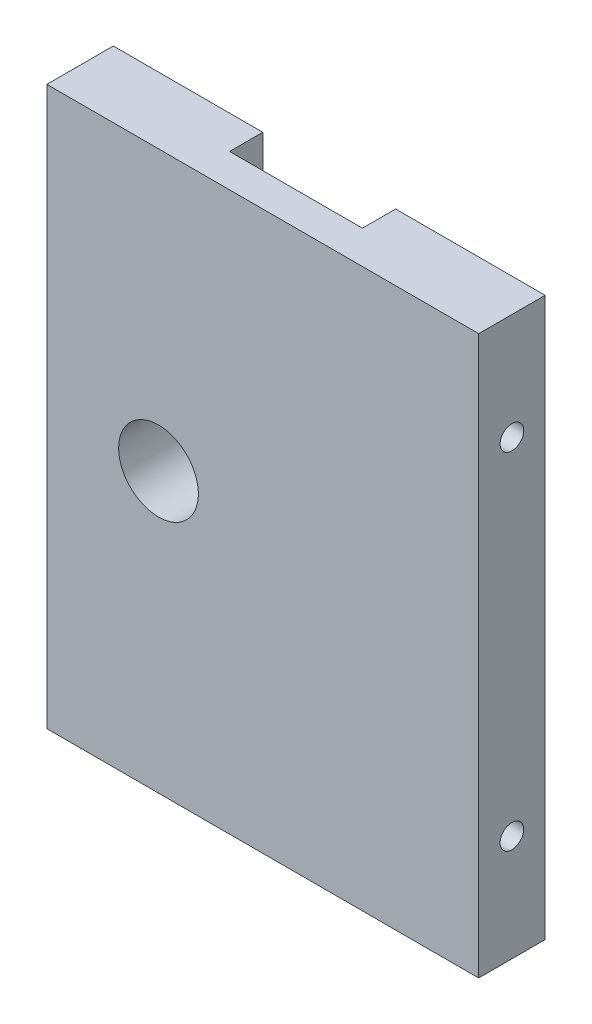
from build123d import *

# Parameters (mm, degrees)
SKETCH1_W                 = 32.5
SKETCH1_H                 = 42
BOSS_EXTRUDE2_DEPTH       = 5
F_2_56_TAPPED_HOLE1_D     = 1.778
F_2_56_TAPPED_HOLE1_DEPTH = 7.46583491
F_2_56_TAPPED_HOLE1_TIP   = 0.53416509
F_2_56_TAPPED_HOLE2_D     = 1.778
F_2_56_TAPPED_HOLE2_DEPTH = 7.46583491
F_2_56_TAPPED_HOLE2_TIP   = 0.53416509
CUT_EXTRUDE1_DEPTH        = 5
SKETCH10_W                = 10
SKETCH10_H                = 6.5
CUT_EXTRUDE2_DEPTH        = 2.5


with BuildPart() as part:
    # Sketch1 → Boss-Extrude2 (new body)
    with BuildSketch(Plane.XY):
        with Locations((16.25, 21)):
            Rectangle(SKETCH1_W, SKETCH1_H)
    extrude(amount=BOSS_EXTRUDE2_DEPTH)

    # #2-56 Tapped Hole1
    with Locations(Plane.ZY):
        with Locations((2.5, 34), (2.5, 8)):
            Hole(F_2_56_TAPPED_HOLE1_D / 2, depth=F_2_56_TAPPED_HOLE1_DEPTH)
            with Locations((0, 0, -(F_2_56_TAPPED_HOLE1_DEPTH + F_2_56_TAPPED_HOLE1_TIP / 2))):  # 118° drill point
                Cone(0, F_2_56_TAPPED_HOLE1_D / 2, F_2_56_TAPPED_HOLE1_TIP, mode=Mode.SUBTRACT)

    # #2-56 Tapped Hole2
    with Locations(Plane(origin=(32.5, 0, 0), x_dir=(0, 0, -1), z_dir=(1, 0, 0))):
        with Locations((-2.5, 34), (-2.5, 8)):
            Hole(F_2_56_TAPPED_HOLE2_D / 2, depth=F_2_56_TAPPED_HOLE2_DEPTH)
            with Locations((0, 0, -(F_2_56_TAPPED_HOLE2_DEPTH + F_2_56_TAPPED_HOLE2_TIP / 2))):  # 118° drill point
                Cone(0, F_2_56_TAPPED_HOLE2_D / 2, F_2_56_TAPPED_HOLE2_TIP, mode=Mode.SUBTRACT)

    # Sketch9 → Cut-Extrude1 (cut)
    with BuildSketch(Plane(origin=(0, 0, 0), x_dir=(-1, 0, 0), z_dir=(0, 0, -1))):
        with BuildLine():
            ThreePointArc((-11.4, 21), (-8.4, 18), (-5.4, 21))
            Line((-5.4, 21), (-8.4, 21))
            Line((-8.4, 21), (-11.4, 21))
        make_face()
        with BuildLine():
            Line((-8.4, 21), (-5.4, 21))
            ThreePointArc((-5.4, 21), (-8.4, 24), (-11.4, 21))
            Line((-11.4, 21), (-8.4, 21))
        make_face()
    extrude(amount=-CUT_EXTRUDE1_DEPTH, mode=Mode.SUBTRACT)

    # Sketch10 → Cut-Extrude2 (cut)
    with BuildSketch(Plane(origin=(0, 0, 0), x_dir=(-1, 0, 0), z_dir=(0, 0, -1))):
        with Locations((-16.25, 38.75)):
            Rectangle(SKETCH10_W, SKETCH10_H)
    extrude(amount=-CUT_EXTRUDE2_DEPTH, mode=Mode.SUBTRACT)


solid = part.part
